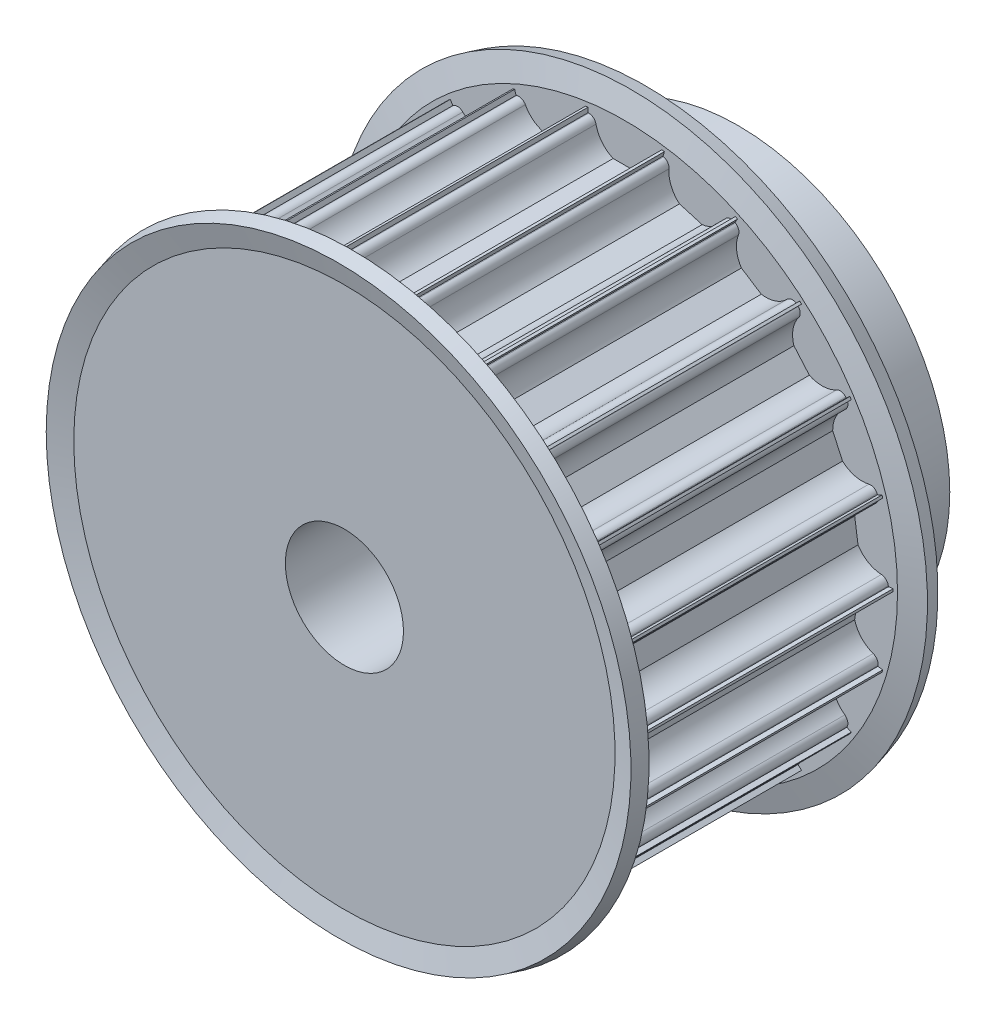
from build123d import *

# Parameters (mm, degrees)
CUT_EXTRUDE1_DEPTH = 30
CIRPATTERN2_COUNT  = 22


with BuildPart() as part:
    # Sketch1 → Revolve1 (revolve)
    with BuildSketch(Plane(origin=(0, 0, 0), x_dir=(0, 0, -1), z_dir=(1, 0, 0))):
        Polygon((0, 6), (0, 27.25), (30, 27.25), (30, 21.5), (40, 21.5), (40, 6), align=None)
    revolve(axis=Axis((0, 0, 0), (0, 0, -1)))

    # Sketch2 → Cut-Extrude1 (cut)
    with BuildSketch(Plane.XY):
        with BuildLine():
            Line((-3.674234614, 26.5), (-3.75, 26.5))
            Line((-3.75, 26.5), (-3.75, 28.5))
            Line((-3.75, 28.5), (3.75, 28.5))
            Line((3.75, 28.5), (3.75, 26.5))
            Line((3.75, 26.5), (3.674234614, 26.5))
            ThreePointArc((3.674234614, 26.5), (3.199892965, 26.330947502), (2.939387691, 25.9))
            ThreePointArc((2.939387691, 25.9), (2.331759211, 24.612435701), (1.198957881, 23.75))
            Line((1.198957881, 23.75), (-1.198957881, 23.75))
            ThreePointArc((-1.198957881, 23.75), (-2.331759211, 24.612435701), (-2.939387691, 25.9))
            ThreePointArc((-2.939387691, 25.9), (-3.199892965, 26.330947502), (-3.674234614, 26.5))
        make_face()
    cut_extrude1 = extrude(amount=-CUT_EXTRUDE1_DEPTH, mode=Mode.SUBTRACT)

    # CirPattern2: Cut-Extrude1 ×22 about axis
    cirpattern2_axis = Axis((0, 0, 0), (0, 0, 1))
    for i in range(1, CIRPATTERN2_COUNT):
        add(cut_extrude1.rotate(cirpattern2_axis, i * 360 / CIRPATTERN2_COUNT), mode=Mode.SUBTRACT)

    # Sketch3 → Revolve2 (revolve)
    with BuildSketch(Plane(origin=(0, 0, 0), x_dir=(0, 0, -1), z_dir=(1, 0, 0))):
        Polygon((30, 21.5), (30, 27.492521254), (30.591966801, 29.701771432), (29.143078062, 30.09), (28.5, 27.69), (28.5, 21.5), align=None)
        Polygon((0, 27.492521254), (-0.591966801, 29.701771432), (0.856921938, 30.09), (1.5, 27.69), (1.5, 21.5), (0, 21.5), align=None)
    revolve(axis=Axis((0, 0, 0), (0, 0, 1)))


solid = part.part
